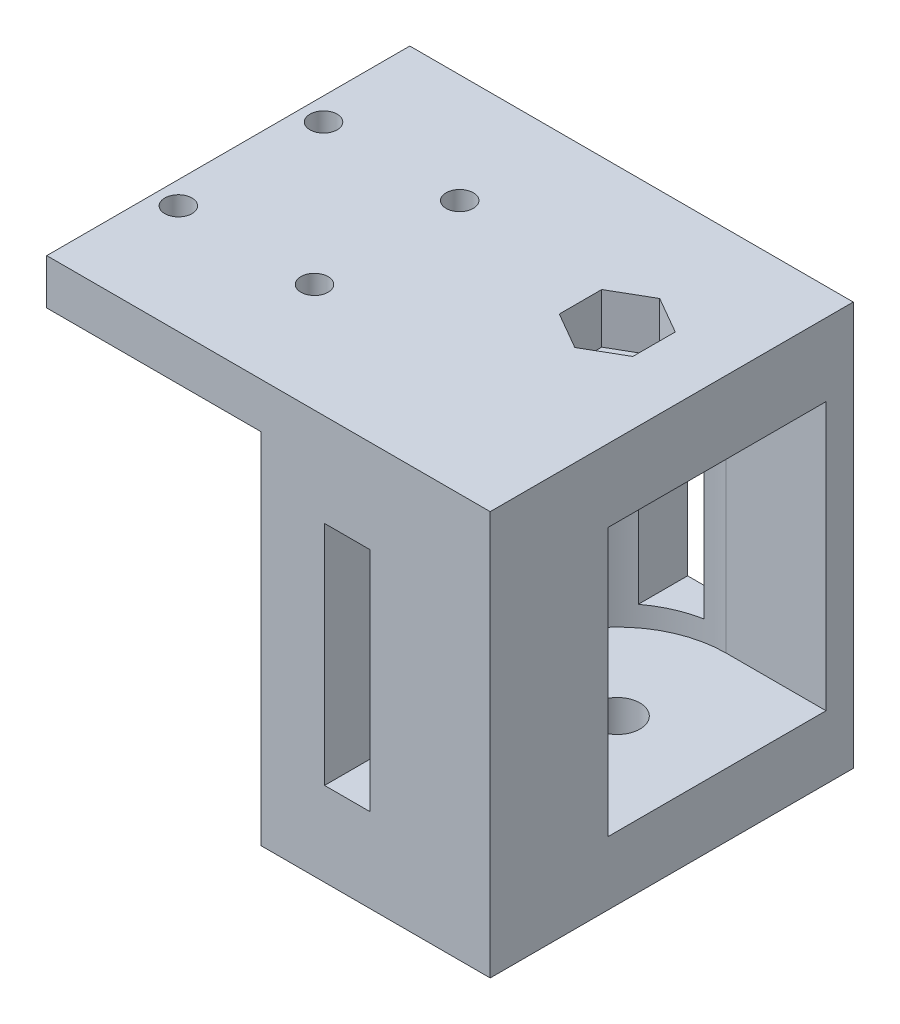
from build123d import *

# Parameters (mm, degrees)
SKETCH1_W                = 5
SKETCH1_H                = 25
BOSS_EXTRUDE1_DEPTH      = 25
BOSS_EXTRUDE1_DEPTH_BACK = 15
CUT_EXTRUDE1_START       = -15.25
CUT_EXTRUDE1_DEPTH       = 29.5
SKETCH5_R                = 2.5
CUT_EXTRUDE4_DEPTH       = 38.5
CUT_EXTRUDE4_DEPTH_BACK  = 8
CUT_EXTRUDE5_DEPTH       = 5.5
SKETCH7_R                = 1.5
CUT_EXTRUDE6_DEPTH       = 45.5


with BuildPart() as part:
    # Sketch1 → Boss-Extrude1 (new body, two sides)
    with BuildSketch(Plane.XY) as boss_extrude1_sk:
        Polygon((23.61, -22.25), (48.86, -22.25), (48.86, 22.25), (0, 22.25), (0, 17.25), (23.61, 17.25), align=None)
        with Locations((33.11, -0.5)):
            Rectangle(SKETCH1_W, SKETCH1_H, mode=Mode.SUBTRACT)
    extrude(amount=BOSS_EXTRUDE1_DEPTH)
    extrude(boss_extrude1_sk.sketch, amount=-BOSS_EXTRUDE1_DEPTH_BACK)

    # Sketch2 → Cut-Extrude1 (cut)
    with BuildSketch(Plane(origin=(0, 0, 0), x_dir=(1, 0, 0), z_dir=(0, 1, 0)).offset(CUT_EXTRUDE1_START)):
        with BuildLine():
            Line((37.86, 12), (48.86, 12))
            Line((48.86, 12), (48.86, -12))
            Line((48.86, -12), (37.86, -12))
            ThreePointArc((37.86, -12), (25.86, 0), (37.86, 12))
        make_face()
    extrude(amount=CUT_EXTRUDE1_DEPTH, mode=Mode.SUBTRACT)

    # Sketch5 → Cut-Extrude4 (cut, two sides)
    with BuildSketch(Plane(origin=(0, -15.25, 0), x_dir=(1, 0, 0), z_dir=(0, 1, 0))) as cut_extrude4_sk:
        with Locations((37.86, 0)):
            Circle(SKETCH5_R)
    extrude(amount=CUT_EXTRUDE4_DEPTH, mode=Mode.SUBTRACT)
    extrude(cut_extrude4_sk.sketch, amount=-CUT_EXTRUDE4_DEPTH_BACK, mode=Mode.SUBTRACT)

    # Sketch6 → Cut-Extrude5 (cut)
    with BuildSketch(Plane(origin=(0, 22.25, 0), x_dir=(1, 0, 0), z_dir=(0, 1, 0))):
        Polygon((41.91, 2.33826859), (37.86, 4.67653718), (33.81, 2.33826859), (33.81, -2.33826859), (37.86, -4.67653718), (41.91, -2.33826859), align=None)
    extrude(amount=-CUT_EXTRUDE5_DEPTH, mode=Mode.SUBTRACT)

    # Sketch7 → Cut-Extrude6 (cut, through all)
    with BuildSketch(Plane(origin=(0, 22.25, 0), x_dir=(1, 0, 0), z_dir=(0, 1, 0))):
        with Locations((2.5, 3)):
            Circle(SKETCH7_R)
        with Locations((17.5, 3)):
            Circle(SKETCH7_R)
        with Locations((17.5, -13)):
            Circle(SKETCH7_R)
        with Locations((2.5, -13)):
            Circle(SKETCH7_R)
    extrude(amount=-CUT_EXTRUDE6_DEPTH, mode=Mode.SUBTRACT)


solid = part.part
